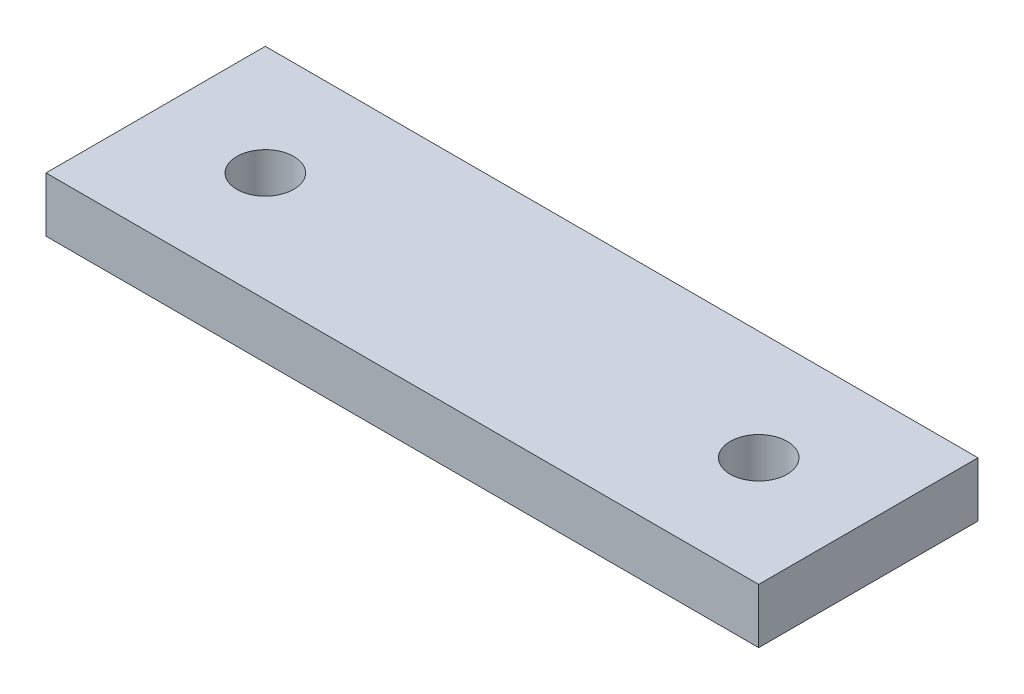
from build123d import *

# Parameters (mm, degrees)
SKETCH1_W           = 82.55
SKETCH1_H           = 25.4
SKETCH1_R           = 3.302
BOSS_EXTRUDE1_DEPTH = 6.35


with BuildPart() as part:
    # Sketch1 → Boss-Extrude1 (new body)
    with BuildSketch(Plane(origin=(0, 0, 0), x_dir=(1, 0, 0), z_dir=(0, 1, 0))):
        with Locations((41.275, 12.7)):
            Rectangle(SKETCH1_W, SKETCH1_H)
        with Locations((12.7, 12.7)):
            Circle(SKETCH1_R, mode=Mode.SUBTRACT)
        with Locations((69.85, 12.7)):
            Circle(SKETCH1_R, mode=Mode.SUBTRACT)
    extrude(amount=BOSS_EXTRUDE1_DEPTH)


solid = part.part
